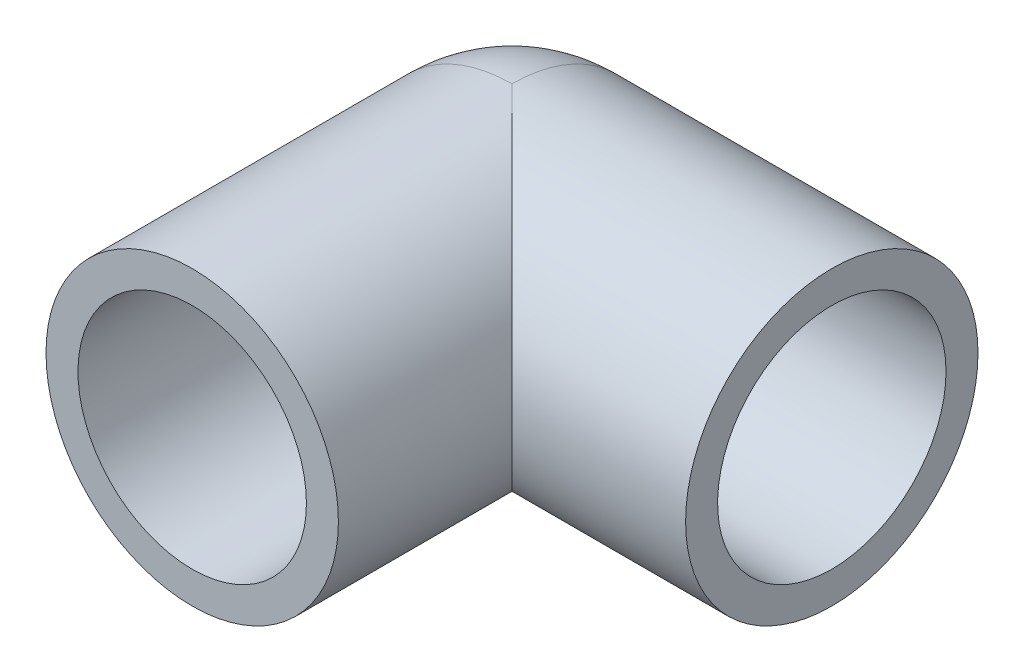
from build123d import *

# Parameters (mm, degrees)
SKETCH_1_R      = 16
SKETCH_1_R_2    = 12.5
EXTRUDE_1_DEPTH = 35
SKETCH_2_R      = 16
SKETCH_2_R_2    = 12.5
EXTRUDE_2_DEPTH = 35
REVOLVE_1_ANGLE = 90


with BuildPart() as part:
    # 草图1 → 凸台-拉伸1 (new body)
    with BuildSketch(Plane.XY):
        Circle(SKETCH_1_R)
        Circle(SKETCH_1_R_2, mode=Mode.SUBTRACT)
    extrude(amount=EXTRUDE_1_DEPTH)

    # 草图2 → 凸台-拉伸2 (add)
    with BuildSketch(Plane(origin=(0, 0, 0), x_dir=(0, 0, -1), z_dir=(1, 0, 0))):
        Circle(SKETCH_2_R)
        Circle(SKETCH_2_R_2, mode=Mode.SUBTRACT)
    extrude(amount=EXTRUDE_2_DEPTH)

    # 草图3 → 旋转1 (revolve)
    with BuildSketch(Plane.XY):
        with BuildLine():
            Line((0, 16), (0, -16))
            ThreePointArc((0, -16), (-16, 0), (0, 16))
        make_face()
    revolve(axis=Axis((0, 16, 0), (0, -1, 0)), revolution_arc=REVOLVE_1_ANGLE)


solid = part.part
